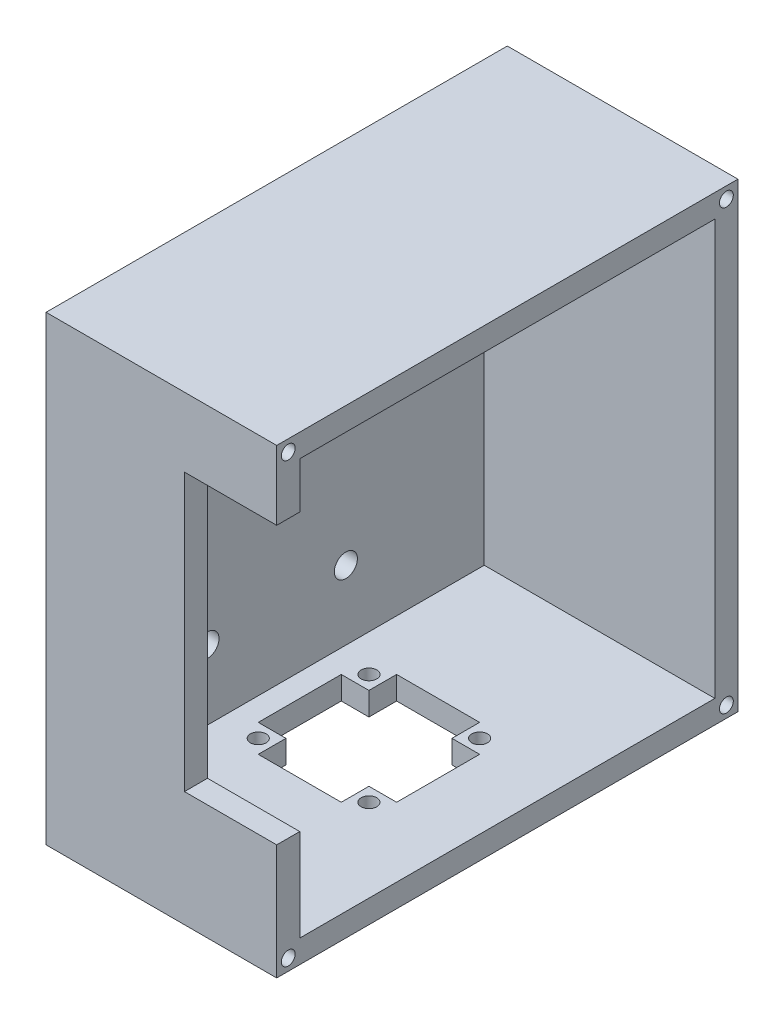
from build123d import *

# Parameters (mm, degrees)
SKETCH7_W            = 100
SKETCH7_H            = 100
BOSS_EXTRUDE2_DEPTH  = 10
SKETCH8_W            = 100
SKETCH8_H            = 100
SKETCH8_W_2          = 90
SKETCH8_H_2          = 90
BOSS_EXTRUDE3_DEPTH  = 50
CHAMFER1_SIZE        = 10
CUT_EXTRUDE5_DEPTH   = 15
FILLET3_R            = 1
SKETCH16_W           = 30
SKETCH16_H           = 30
CUT_EXTRUDE6_DEPTH   = 10
SKETCH17_W           = 6
SKETCH17_H           = 6
SKETCH17_R           = 1.7
BOSS_EXTRUDE4_DEPTH  = 5
LPATTERN2_COUNT      = 2
LPATTERN2_PITCH      = 24
LPATTERN2_COUNT_DIR2 = 2
LPATTERN2_PITCH_DIR2 = 24
SKETCH18_R           = 2.5
CUT_EXTRUDE7_DEPTH   = 10
LPATTERN3_COUNT      = 2
LPATTERN3_PITCH      = 30
LPATTERN3_COUNT_DIR2 = 2
LPATTERN3_PITCH_DIR2 = 50
SKETCH19_W           = 20
SKETCH19_H           = 60
CUT_EXTRUDE8_DEPTH   = 10
SKETCH20_R           = 1.5
CUT_EXTRUDE9_DEPTH   = 5
LPATTERN4_COUNT      = 2
LPATTERN4_PITCH      = 95
LPATTERN4_COUNT_DIR2 = 2
LPATTERN4_PITCH_DIR2 = 95


with BuildPart() as part:
    # Sketch7 → Boss-Extrude2 (new body)
    with BuildSketch(Plane(origin=(0, 0, 0), x_dir=(0, 0, -1), z_dir=(1, 0, 0))):
        Rectangle(SKETCH7_W, SKETCH7_H)
    extrude(amount=BOSS_EXTRUDE2_DEPTH)

    # Sketch8 → Boss-Extrude3 (add)
    with BuildSketch(Plane(origin=(10, 0, 0), x_dir=(0, 0, -1), z_dir=(1, 0, 0))):
        Rectangle(SKETCH8_W, SKETCH8_H)
        Rectangle(SKETCH8_W_2, SKETCH8_H_2, mode=Mode.SUBTRACT)
    extrude(amount=BOSS_EXTRUDE3_DEPTH)

    # Chamfer1
    chamfer1_edges = [part.edges().sort_by_distance(p)[0] for p in [
        (0, 50, 0),
        (0, 0, -50),
        (0, -50, 0),
        (0, 0, 50),
    ]]
    chamfer(chamfer1_edges, length=CHAMFER1_SIZE)

    # Sketch14 → Cut-Extrude5 (cut)
    with BuildSketch(Plane.ZY):
        with BuildLine():
            Line((-25, 37.5), (25, 37.5))
            ThreePointArc((25, 37.5), (30, 32.5), (25, 27.5))
            Line((25, 27.5), (-25, 27.5))
            ThreePointArc((-25, 27.5), (-30, 32.5), (-25, 37.5))
        make_face()
    extrude(amount=-CUT_EXTRUDE5_DEPTH, mode=Mode.SUBTRACT)

    # Fillet3
    fillet3_edges = [part.edges().sort_by_distance(p)[0] for p in [
        (10, 27.5, 0),
        (10, 32.5, 30),
        (10, 37.5, 0),
        (10, 32.5, -30),
        (0, 32.5, -30),
        (0, 27.5, 0),
        (0, 32.5, 30),
        (0, 37.5, 0),
    ]]
    fillet(fillet3_edges, radius=FILLET3_R)

    # Sketch16 → Cut-Extrude6 (cut)
    with BuildSketch(Plane.XZ.offset(50)):
        with Locations((30, 0)):
            Rectangle(SKETCH16_W, SKETCH16_H)
    extrude(amount=-CUT_EXTRUDE6_DEPTH, mode=Mode.SUBTRACT)

    # Sketch17 → Boss-Extrude4 (add)
    with BuildSketch(Plane.XZ.offset(50)):
        with Locations((18, 12)):
            Rectangle(SKETCH17_W, SKETCH17_H)
        with Locations((18, 12)):
            Circle(SKETCH17_R, mode=Mode.SUBTRACT)
    boss_extrude4 = extrude(amount=-BOSS_EXTRUDE4_DEPTH)

    # LPattern2: Boss-Extrude4 2 × 2
    with Locations(*[(i * LPATTERN2_PITCH, 0, -j * LPATTERN2_PITCH_DIR2) for i in range(LPATTERN2_COUNT) for j in range(LPATTERN2_COUNT_DIR2) if (i, j) != (0, 0)]):
        add(boss_extrude4)

    # Sketch18 → Cut-Extrude7 (cut)
    with BuildSketch(Plane.ZY):
        with Locations((-15, 20)):
            Circle(SKETCH18_R)
    cut_extrude7 = extrude(amount=-CUT_EXTRUDE7_DEPTH, mode=Mode.SUBTRACT)

    # LPattern3: Cut-Extrude7 2 × 2
    with Locations(*[(0, -j * LPATTERN3_PITCH_DIR2, i * LPATTERN3_PITCH) for i in range(LPATTERN3_COUNT) for j in range(LPATTERN3_COUNT_DIR2) if (i, j) != (0, 0)]):
        add(cut_extrude7, mode=Mode.SUBTRACT)

    # Sketch19 → Cut-Extrude8 (cut)
    with BuildSketch(Plane.XY.offset(50)):
        with Locations((50, 5)):
            Rectangle(SKETCH19_W, SKETCH19_H)
    extrude(amount=-CUT_EXTRUDE8_DEPTH, mode=Mode.SUBTRACT)

    # Sketch20 → Cut-Extrude9 (cut)
    with BuildSketch(Plane(origin=(60, 0, 0), x_dir=(0, 0, -1), z_dir=(1, 0, 0))):
        with Locations((-47.5, 47.5)):
            Circle(SKETCH20_R)
    cut_extrude9 = extrude(amount=-CUT_EXTRUDE9_DEPTH, mode=Mode.SUBTRACT)

    # LPattern4: Cut-Extrude9 2 × 2
    with Locations(*[(0, -j * LPATTERN4_PITCH_DIR2, -i * LPATTERN4_PITCH) for i in range(LPATTERN4_COUNT) for j in range(LPATTERN4_COUNT_DIR2) if (i, j) != (0, 0)]):
        add(cut_extrude9, mode=Mode.SUBTRACT)


solid = part.part
